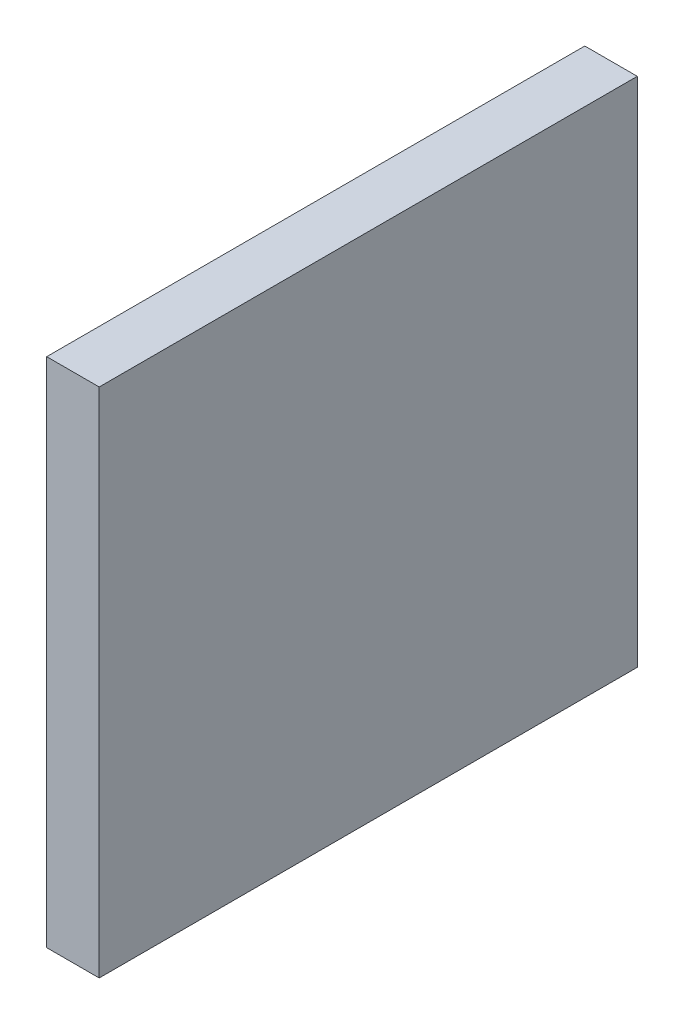
from build123d import *

# Parameters (mm, degrees)
SKETCH3_W           = 41
SKETCH3_H           = 39
BOSS_EXTRUDE2_DEPTH = 4


with BuildPart() as part:
    # Sketch3 → Boss-Extrude2 (new body)
    with BuildSketch(Plane(origin=(0, 0, 0), x_dir=(0, 0, -1), z_dir=(1, 0, 0))):
        with Locations((20.5, 19.5)):
            Rectangle(SKETCH3_W, SKETCH3_H)
    extrude(amount=BOSS_EXTRUDE2_DEPTH)


solid = part.part
